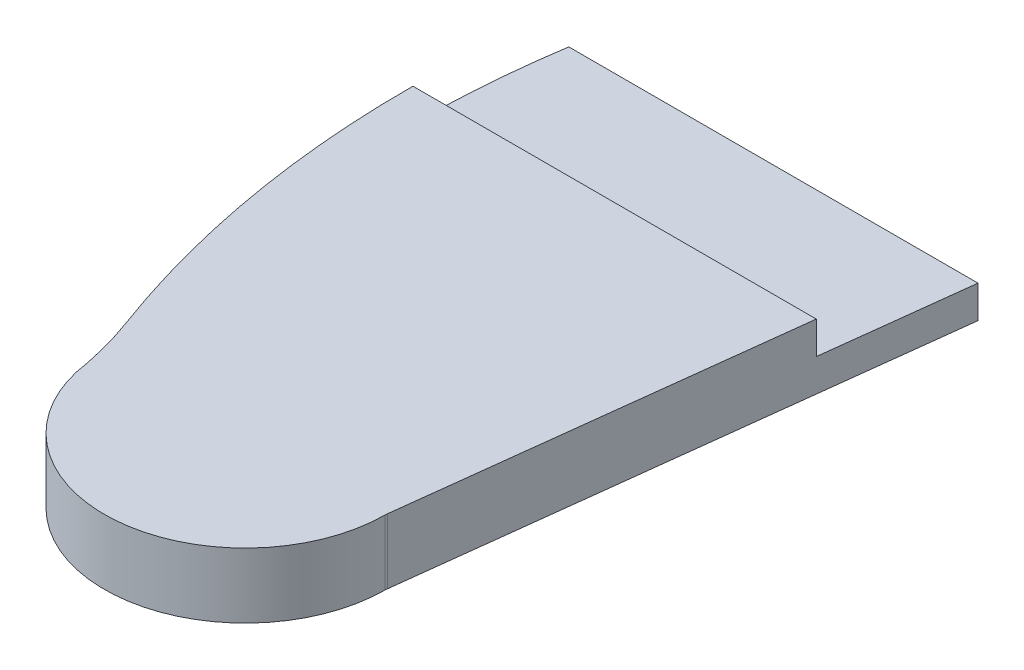
from build123d import *

# Parameters (mm, degrees)
BOSS_EXTRU_7_DEPTH      = 30
ECHELLE1_SCALE          = 0.45
ESQUISSE2_W             = 105.662811699
ESQUISSE2_H             = 110
ENL_V_MAT_EXTRU_1_DEPTH = 22.7500001
ESQUISSE3_W             = 30
ESQUISSE3_H             = 6.75
ENL_V_MAT_EXTRU_3_DEPTH = 560.216594492


with BuildPart() as part:
    # Esquisse1 → Boss.-Extru.7 (new body)
    with BuildSketch(Plane(origin=(0, 0, 0), x_dir=(1, 0, 0), z_dir=(0, 1, 0))):
        with BuildLine():
            Line((130.068099718, -349.430080583), (176.932850794, 42.776117227))
            ThreePointArc((176.932850794, 42.776117227), (140.21219631, 65.055468432), (104.297030791, 41.49964449))
            ThreePointArc((104.297030791, 41.49964449), (83.352659725, 49.557480865), (63.285053961, 39.513248426))
            ThreePointArc((63.285053961, 39.513248426), (24.333712458, 39.346724586), (0.792917217, 8.313424819))
            add(Edge.make_bspline(
                [(0.792917217, 8.313424819), (-2.209813164, -2.681427076), (-5.40896856, -13.621959217)],
                knots=[0.221662646, 0.221662646, 0.221662646, 1, 1, 1], degree=2))
            ThreePointArc((-5.40896856, -13.621959217), (-34.929657478, -173.074330833), (-6.757332127, -332.770448419))
            add(Edge.make_bspline(
                [(-6.757332127, -332.770448419), (-2.007582254, -345.453681588), (0.57620201, -358.635638513)],
                knots=[0.963730152, 0.963730152, 0.963730152, 1.791334476, 1.791334476, 1.791334476], degree=2))
            ThreePointArc((0.57620201, -358.635638513), (69.060806185, -414.873028703), (129.997803695, -350.534335844))
            ThreePointArc((129.997803695, -350.534335844), (130.017666903, -349.981235195), (130.068099718, -349.430080583))
        make_face()
    extrude(amount=BOSS_EXTRU_7_DEPTH)


with BuildPart() as part_1:
    # Echelle1: scaled about (67.671552852, 15, 164.896156294)
    add(part.part.scale(ECHELLE1_SCALE).moved(Location((37.219354069, 8.25, 90.692885962))))

    # Esquisse2 → Enlèv. mat.-Extru.1 (cut, through all)
    with BuildSketch(Plane(origin=(0, 0, 0), x_dir=(1, 0, 0), z_dir=(0, 1, 0))):
        with Locations((71.147737752, -83.392019497)):
            Rectangle(ESQUISSE2_W, ESQUISSE2_H)
    extrude(amount=ENL_V_MAT_EXTRU_1_DEPTH, mode=Mode.SUBTRACT)

    # Esquisse3 → Enlèv. mat.-Extru.3 (cut, through all)
    with BuildSketch(Plane(origin=(580.715772067, 0, 0), x_dir=(0, 0, -1), z_dir=(1, 0, 0))):
        with Locations((-153.392019497, 18.375)):
            Rectangle(ESQUISSE3_W, ESQUISSE3_H)
    extrude(amount=-ENL_V_MAT_EXTRU_3_DEPTH, mode=Mode.SUBTRACT)


solid = part_1.part
